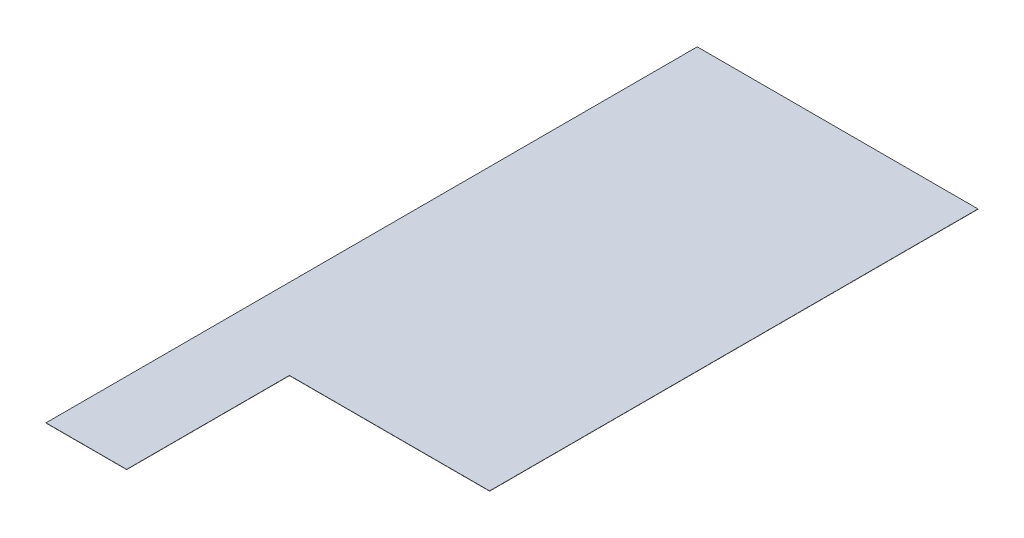
from build123d import *

# Parameters (mm, degrees)
SKETCH1_W               = 2102.612
SKETCH1_H               = 4876.8
BOSS_EXTRUDE1_DEPTH     = 1.5875
SKETCH2_W               = 1498.6
SKETCH2_H               = 1219.2
CUT_EXTRUDE1_DEPTH      = 1
CUT_EXTRUDE1_DEPTH_BACK = 2.5875


with BuildPart() as part:
    # Sketch1 → Boss-Extrude1 (new body)
    with BuildSketch(Plane(origin=(0, 0, 0), x_dir=(1, 0, 0), z_dir=(0, 1, 0))):
        Rectangle(SKETCH1_W, SKETCH1_H)
    extrude(amount=BOSS_EXTRUDE1_DEPTH)

    # Sketch2 → Cut-Extrude1 (cut, two sides)
    with BuildSketch(Plane(origin=(0, 1.5875, 0), x_dir=(1, 0, 0), z_dir=(0, 1, 0))) as cut_extrude1_sk:
        with Locations((302.006, -1828.8)):
            Rectangle(SKETCH2_W, SKETCH2_H)
    extrude(amount=CUT_EXTRUDE1_DEPTH, mode=Mode.SUBTRACT)
    extrude(cut_extrude1_sk.sketch, amount=-CUT_EXTRUDE1_DEPTH_BACK, mode=Mode.SUBTRACT)


solid = part.part
